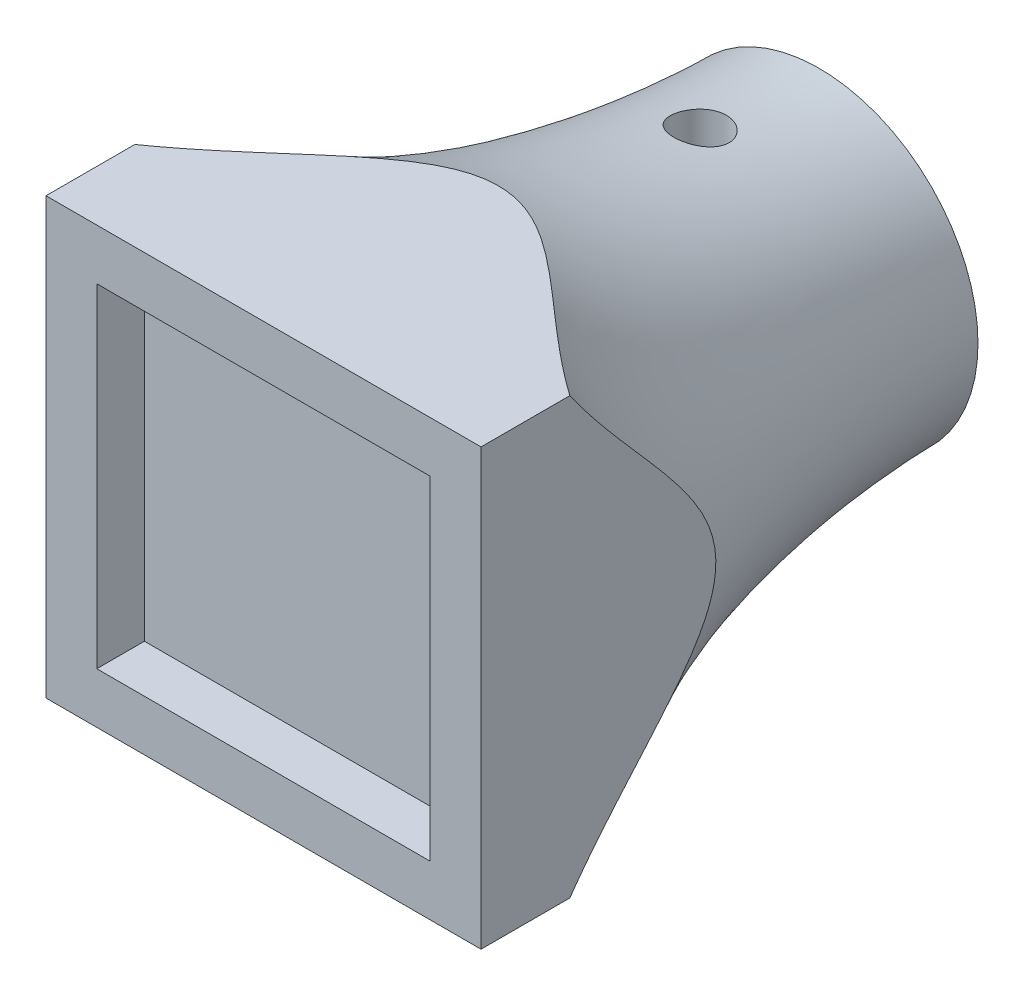
from build123d import *

# Parameters (mm, degrees)
SKETCH1_R           = 10
BOSS_EXTRUDE1_DEPTH = 30
SKETCH2_W           = 27.4
SKETCH2_H           = 27.4
BOSS_EXTRUDE2_DEPTH = 5
SKETCH3_W           = 21
SKETCH3_H           = 21
CUT_EXTRUDE1_DEPTH  = 3
SKETCH7_W           = 47.139349652
SKETCH7_H           = 47.139349652
SKETCH7_W_2         = 27.4
SKETCH7_H_2         = 27.4
CUT_EXTRUDE2_DEPTH  = 78
CUT_EXTRUDE3_DEPTH  = 15
CUT_EXTRUDE4_DEPTH  = 3
SKETCH11_R          = 1.65
CUT_EXTRUDE5_DEPTH  = 12


with BuildPart() as part:
    # Sketch1 → Boss-Extrude1 (new body)
    with BuildSketch(Plane.XY):
        Circle(SKETCH1_R)
    extrude(amount=BOSS_EXTRUDE1_DEPTH)

    # Sketch2 → Boss-Extrude2 (add)
    with BuildSketch(Plane.XY.offset(30)):
        Rectangle(SKETCH2_W, SKETCH2_H)
    extrude(amount=BOSS_EXTRUDE2_DEPTH)

    # Sketch3 → Cut-Extrude1 (cut)
    with BuildSketch(Plane.XY.offset(35)):
        Rectangle(SKETCH3_W, SKETCH3_H)
    extrude(amount=-CUT_EXTRUDE1_DEPTH, mode=Mode.SUBTRACT)

    # Sketch6 → Revolve1 (revolve)
    with BuildSketch(Plane(origin=(0, 0, 0), x_dir=(0, 0, -1), z_dir=(1, 0, 0))):
        with BuildLine():
            Line((-30, 0), (-30, 20))
            add(Edge.make_bspline(
                [(-30, 20), (-22.099947356, 11.248565128), (-4.613209845, 10), (0, 10)],
                knots=[0, 0, 0, 0, 1, 1, 1, 1], degree=3))
            Line((0, 10), (0, 0))
            Line((0, 0), (-30, 0))
        make_face()
    revolve(axis=Axis((0, 0, 63.541170981), (0, 0, 1)))

    # Sketch7 → Cut-Extrude2 (cut)
    with BuildSketch(Plane.XY.offset(30)):
        Rectangle(SKETCH7_W, SKETCH7_H)
        Rectangle(SKETCH7_W_2, SKETCH7_H_2, mode=Mode.SUBTRACT)
    extrude(amount=-CUT_EXTRUDE2_DEPTH, mode=Mode.SUBTRACT)

    # Sketch8 → Cut-Extrude3 (cut)
    with BuildSketch(Plane(origin=(0, 0, 0), x_dir=(-1, 0, 0), z_dir=(0, 0, -1))):
        with BuildLine():
            Line((-1.616322988, 2.1), (1.616322988, 2.1))
            ThreePointArc((1.616322988, 2.1), (0, -2.65), (-1.616322988, 2.1))
        make_face()
    extrude(amount=-CUT_EXTRUDE3_DEPTH, mode=Mode.SUBTRACT)

    # Sketch10 → Cut-Extrude4 (cut)
    with BuildSketch(Plane.XZ.offset(-2.1)):
        Polygon((0, 4.035898385), (3, 5.767949192), (3, 9.232050808), (0, 10.964101615), (-15.10195651, 10.964101615), (-15.10195651, 4.035898385), align=None)
    extrude(amount=-CUT_EXTRUDE4_DEPTH, mode=Mode.SUBTRACT)

    # Sketch11 → Cut-Extrude5 (cut)
    with BuildSketch(Plane.XZ.offset(-5.1)):
        with Locations((0, 7.5)):
            Circle(SKETCH11_R)
    extrude(amount=-CUT_EXTRUDE5_DEPTH, mode=Mode.SUBTRACT)


solid = part.part
